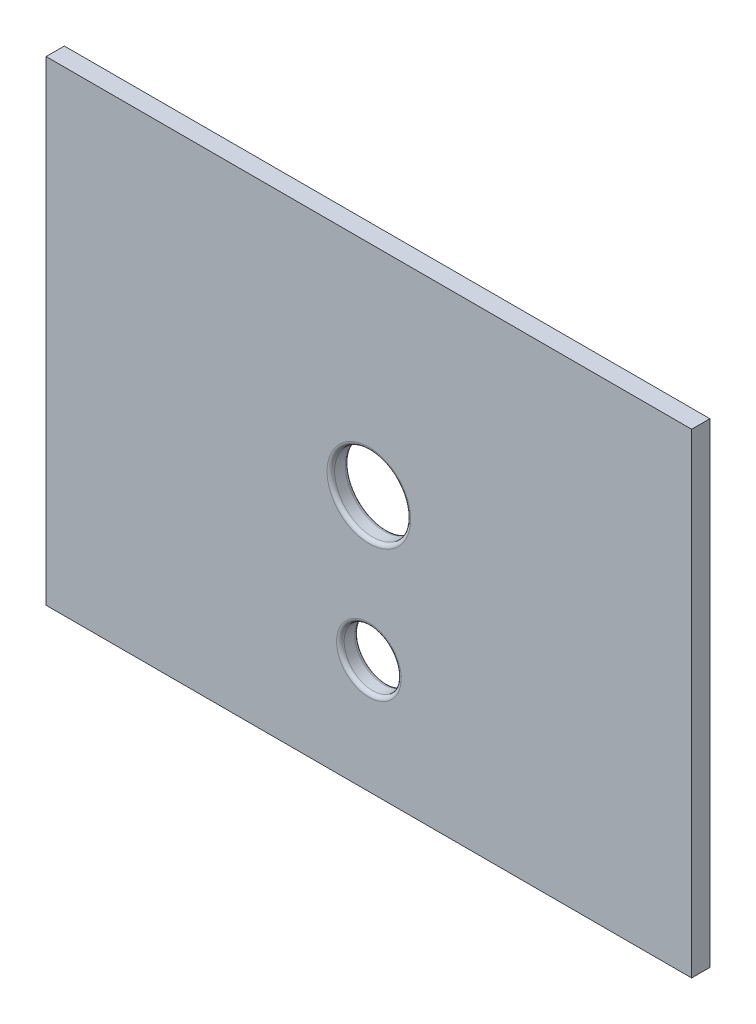
from build123d import *

# Parameters (mm, degrees)
SKETCH1_W           = 169.8
SKETCH1_H           = 125
SKETCH1_R           = 10
BOSS_EXTRUDE1_DEPTH = 4.8
SKETCH2_R           = 7.5
CUT_EXTRUDE1_DEPTH  = 5.8
FILLET1_R           = 1


with BuildPart() as part:
    # Sketch1 → Boss-Extrude1 (new body)
    with BuildSketch(Plane.XY):
        Rectangle(SKETCH1_W, SKETCH1_H)
        with Locations((0, 5)):
            Circle(SKETCH1_R, mode=Mode.SUBTRACT)
    extrude(amount=BOSS_EXTRUDE1_DEPTH)

    # Sketch2 → Cut-Extrude1 (cut, through all)
    with BuildSketch(Plane.XY.offset(4.8)):
        with Locations((0, -32.5)):
            Circle(SKETCH2_R)
    extrude(amount=-CUT_EXTRUDE1_DEPTH, mode=Mode.SUBTRACT)

    # Fillet1
    fillet1_edges = [part.edges().sort_by_distance(p)[0] for p in [
        (-10, 5, 0),
        (-10, 5, 4.8),
        (-7.5, -32.5, 0),
        (-7.5, -32.5, 4.8),
    ]]
    fillet(fillet1_edges, radius=FILLET1_R)


solid = part.part
